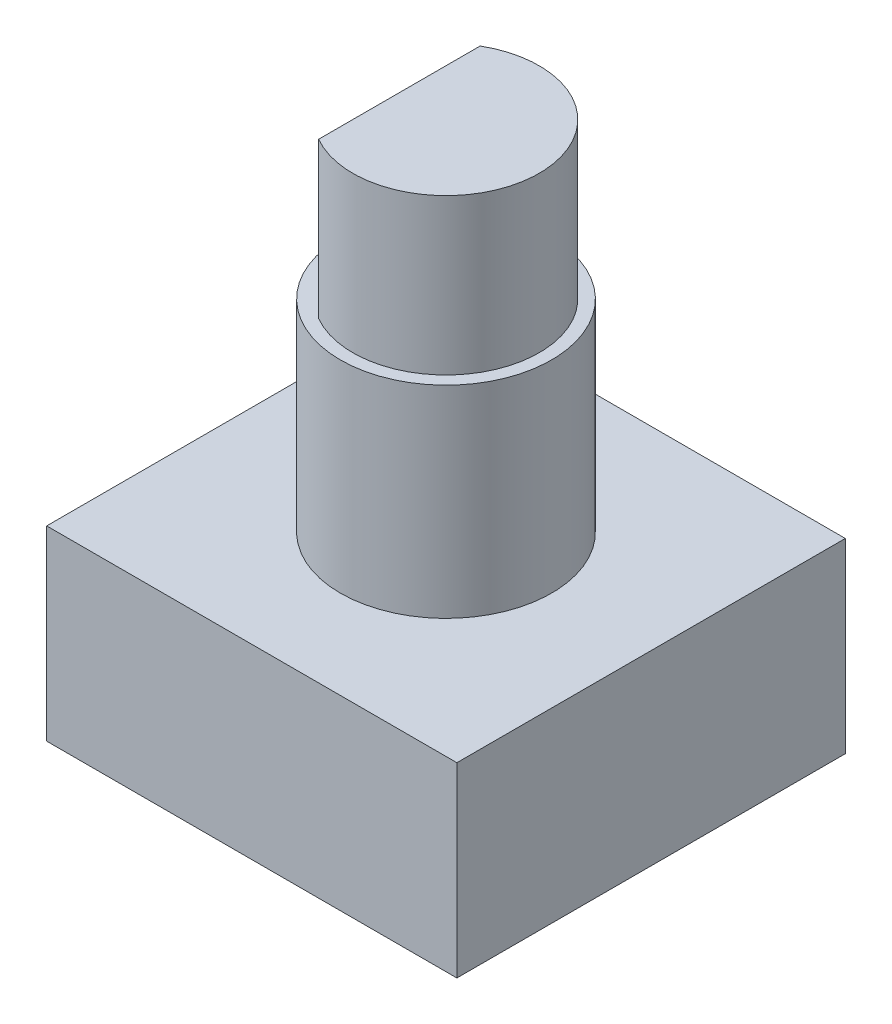
from build123d import *

# Parameters (mm, degrees)
SKETCH1_W           = 13.2
SKETCH1_H           = 12.5
BOSS_EXTRUDE1_DEPTH = 6
SKETCH2_R           = 3.4
BOSS_EXTRUDE2_DEPTH = 6.5
BOSS_EXTRUDE3_DEPTH = 5


with BuildPart() as part:
    # Sketch1 → Boss-Extrude1 (new body)
    with BuildSketch(Plane(origin=(0, 0, 0), x_dir=(1, 0, 0), z_dir=(0, 1, 0))):
        Rectangle(SKETCH1_W, SKETCH1_H)
    extrude(amount=BOSS_EXTRUDE1_DEPTH)

    # Sketch2 → Boss-Extrude2 (add)
    with BuildSketch(Plane(origin=(0, 6, 0), x_dir=(1, 0, 0), z_dir=(0, 1, 0))):
        Circle(SKETCH2_R)
    extrude(amount=BOSS_EXTRUDE2_DEPTH)

    # Sketch3 → Boss-Extrude3 (add)
    with BuildSketch(Plane(origin=(0, 12.5, 0), x_dir=(1, 0, 0), z_dir=(0, 1, 0))):
        with BuildLine():
            Line((-1.5, -2.598076211), (-1.5, 2.598076211))
            ThreePointArc((-1.5, 2.598076211), (3, 0), (-1.5, -2.598076211))
        make_face()
    extrude(amount=BOSS_EXTRUDE3_DEPTH)


solid = part.part
